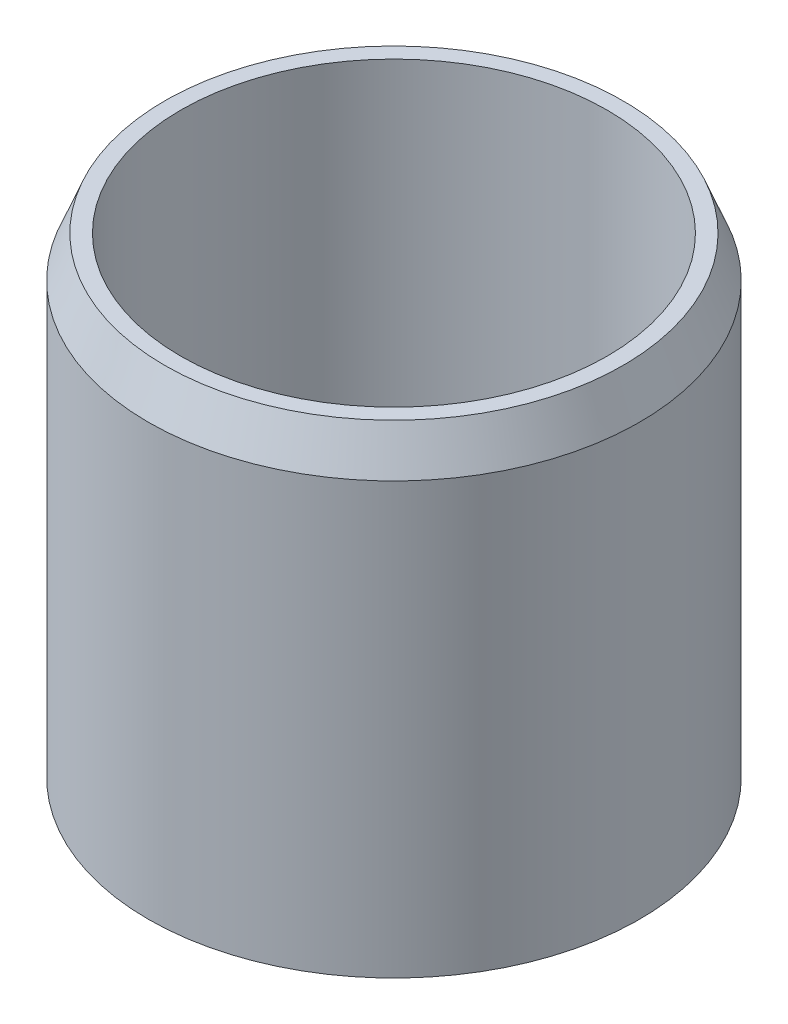
from build123d import *

# Parameters (mm, degrees)
SKETCH1_R           = 38.0365
SKETCH1_R_2         = 6.5024
SKETCH1_R_3         = 7.62
BOSS_EXTRUDE1_DEPTH = 9.525
SKETCH2_R           = 38.0365
SKETCH2_R_2         = 33.02
BOSS_EXTRUDE2_DEPTH = 63.5
SKETCH3_R           = 12.7
SKETCH3_R_2         = 6.5024
BOSS_EXTRUDE3_DEPTH = 15.875
CHAMFER1_SIZE       = 6.35
CHAMFER1_SIZE2      = 2.54
SKETCH4_R           = 12.7
BOSS_EXTRUDE4_DEPTH = 6.35
FILLET1_R           = 2.54


with BuildPart() as part:
    # Sketch1 → Boss-Extrude1 (new body)
    with BuildSketch(Plane(origin=(0, 0, 0), x_dir=(1, 0, 0), z_dir=(0, 1, 0))):
        Circle(SKETCH1_R)
        Circle(SKETCH1_R_2, mode=Mode.SUBTRACT)
        with Locations((0, 22.86)):
            Circle(SKETCH1_R_3, mode=Mode.SUBTRACT)
        with Locations((21.741151963, 7.064128491)):
            Circle(SKETCH1_R_3, mode=Mode.SUBTRACT)
        with Locations((13.436770867, -18.494128491)):
            Circle(SKETCH1_R_3, mode=Mode.SUBTRACT)
        with Locations((-13.436770867, -18.494128491)):
            Circle(SKETCH1_R_3, mode=Mode.SUBTRACT)
        with Locations((-21.741151963, 7.064128491)):
            Circle(SKETCH1_R_3, mode=Mode.SUBTRACT)
    extrude(amount=BOSS_EXTRUDE1_DEPTH)

    # Sketch2 → Boss-Extrude2 (add)
    with BuildSketch(Plane(origin=(0, 9.525, 0), x_dir=(1, 0, 0), z_dir=(0, 1, 0))):
        Circle(SKETCH2_R)
        Circle(SKETCH2_R_2, mode=Mode.SUBTRACT)
    extrude(amount=BOSS_EXTRUDE2_DEPTH)

    # Sketch3 → Boss-Extrude3 (add)
    with BuildSketch(Plane(origin=(0, 9.525, 0), x_dir=(1, 0, 0), z_dir=(0, 1, 0))):
        Circle(SKETCH3_R)
        Circle(SKETCH3_R_2, mode=Mode.SUBTRACT)
    extrude(amount=BOSS_EXTRUDE3_DEPTH)

    # Chamfer1
    chamfer1_edges = [part.edges().sort_by_distance(p)[0] for p in [
        (-38.0365, 73.025, 0),
    ]]
    chamfer1_side = [part.faces().sort_by_distance(p)[0] for p in [
        (-38.0365, 36.5125, 0),
    ]]
    chamfer(chamfer1_edges, length=CHAMFER1_SIZE, length2=CHAMFER1_SIZE2, reference=chamfer1_side[0])

    # Sketch4 → Boss-Extrude4 (add)
    with BuildSketch(Plane(origin=(0, 25.4, 0), x_dir=(1, 0, 0), z_dir=(0, 1, 0))):
        Circle(SKETCH4_R)
    extrude(amount=BOSS_EXTRUDE4_DEPTH)

    # Fillet1
    fillet1_edges = [part.edges().sort_by_distance(p)[0] for p in [
        (-12.7, 31.75, 0),
    ]]
    fillet(fillet1_edges, radius=FILLET1_R)


solid = part.part
